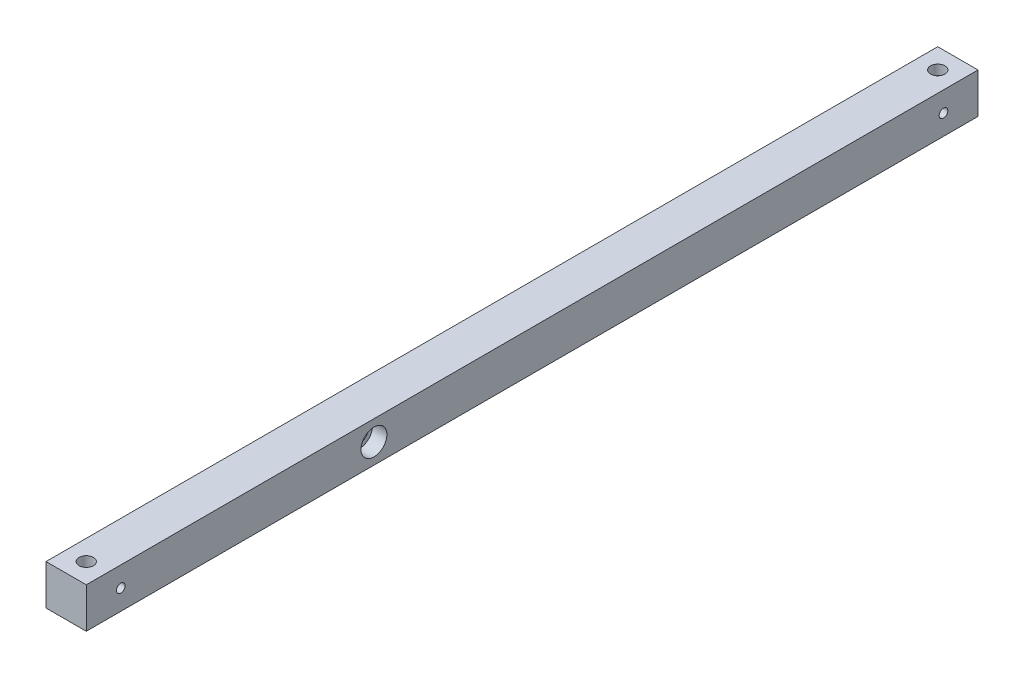
from build123d import *

# Parameters (mm, degrees)
IZIM1_W                     = 28
IZIM1_H                     = 28
Y_KSEKLIK_EKSTR_ZYON1_DEPTH = 620
IZIM3_R                     = 5
KES_EKSTR_ZYON2_DEPTH       = 7
IZIM4_R                     = 3
KES_EKSTR_ZYON3_DEPTH       = 29
IZIM5_R                     = 6
KES_EKSTR_ZYON4_DEPTH       = 29
IZIM6_R                     = 9
KES_EKSTR_ZYON5_DEPTH       = 10
KES_EKSTR_ZYON6_REACH       = 30
IZIM7_R                     = 3
IZIM9_R                     = 5
KES_EKSTR_ZYON8_DEPTH       = 7


with BuildPart() as part:
    # Çizim1 → Yükseklik-Ekstrüzyon1 (new body)
    with BuildSketch(Plane.XY):
        Rectangle(IZIM1_W, IZIM1_H)
    extrude(amount=Y_KSEKLIK_EKSTR_ZYON1_DEPTH)

    # Çizim3 → Kes-Ekstrüzyon2 (cut)
    with BuildSketch(Plane(origin=(0, 14, 0), x_dir=(1, 0, 0), z_dir=(0, 1, 0))):
        with Locations((0, -14)):
            Circle(IZIM3_R)
        with Locations((0, -606)):
            Circle(IZIM3_R)
    extrude(amount=-KES_EKSTR_ZYON2_DEPTH, mode=Mode.SUBTRACT)

    # Çizim4 → Kes-Ekstrüzyon3 (cut, through all)
    with BuildSketch(Plane(origin=(0, 14, 0), x_dir=(1, 0, 0), z_dir=(0, 1, 0))):
        with Locations((0, -606)):
            Circle(IZIM4_R)
        with Locations((0, -14)):
            Circle(IZIM4_R)
    extrude(amount=-KES_EKSTR_ZYON3_DEPTH, mode=Mode.SUBTRACT)

    # Çizim5 → Kes-Ekstrüzyon4 (cut, through all)
    with BuildSketch(Plane(origin=(14, 0, 0), x_dir=(0, 0, -1), z_dir=(1, 0, 0))):
        with Locations((-420, 0)):
            Circle(IZIM5_R)
    extrude(amount=-KES_EKSTR_ZYON4_DEPTH, mode=Mode.SUBTRACT)

    # Çizim6 → Kes-Ekstrüzyon5 (cut)
    with BuildSketch(Plane(origin=(14, 0, 0), x_dir=(0, 0, -1), z_dir=(1, 0, 0))):
        with Locations((-420, 0)):
            Circle(IZIM6_R)
    extrude(amount=-KES_EKSTR_ZYON5_DEPTH, mode=Mode.SUBTRACT)

    # Çizim7 → Kes-Ekstrüzyon6 (cut, up to next)
    with BuildSketch(Plane(origin=(14, 0, 0), x_dir=(0, 0, -1), z_dir=(1, 0, 0)), mode=Mode.PRIVATE) as kes_ekstr_zyon6_sk1:
        with Locations((-24, 0)):
            Circle(IZIM7_R)
    kes_ekstr_zyon6_tool1 = extrude(kes_ekstr_zyon6_sk1.sketch, amount=-KES_EKSTR_ZYON6_REACH, mode=Mode.PRIVATE) & part.part
    add(kes_ekstr_zyon6_tool1.solids().sort_by_distance((14, 0, 24))[0], mode=Mode.SUBTRACT)
    # Çizim7 → Kes-Ekstrüzyon6 (cut, up to next)
    with BuildSketch(Plane(origin=(14, 0, 0), x_dir=(0, 0, -1), z_dir=(1, 0, 0)), mode=Mode.PRIVATE) as kes_ekstr_zyon6_sk2:
        with Locations((-596, 0)):
            Circle(IZIM7_R)
    kes_ekstr_zyon6_tool2 = extrude(kes_ekstr_zyon6_sk2.sketch, amount=-KES_EKSTR_ZYON6_REACH, mode=Mode.PRIVATE) & part.part
    add(kes_ekstr_zyon6_tool2.solids().sort_by_distance((14, 0, 596))[0], mode=Mode.SUBTRACT)

    # Çizim9 → Kes-Ekstrüzyon8 (cut)
    with BuildSketch(Plane.ZY.offset(14)):
        with Locations((596, 0)):
            Circle(IZIM9_R)
        with Locations((24, 0)):
            Circle(IZIM9_R)
    extrude(amount=-KES_EKSTR_ZYON8_DEPTH, mode=Mode.SUBTRACT)


solid = part.part
